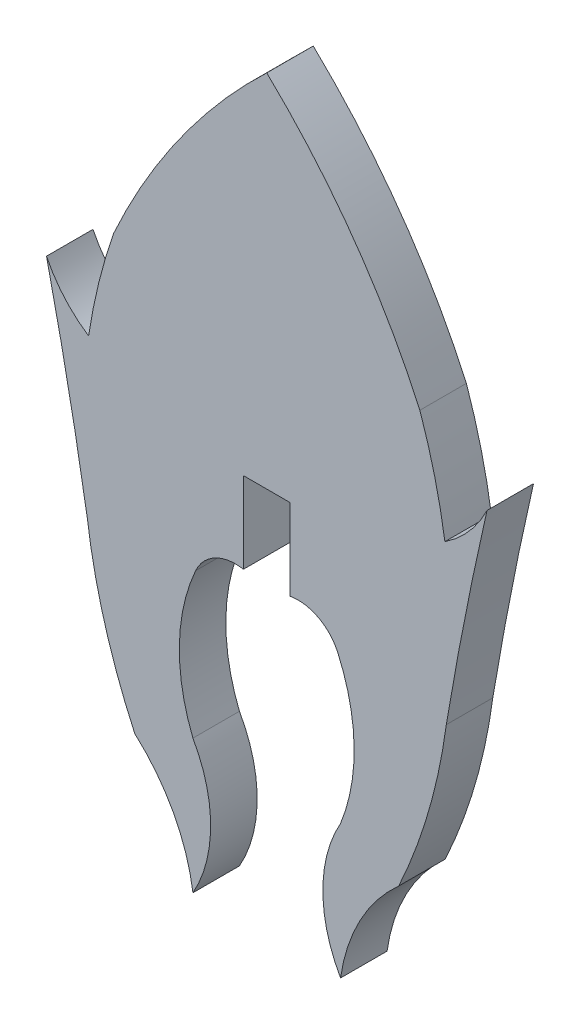
from build123d import *

# Parameters (mm, degrees)
BOSS_EXTRUDE1_DEPTH = 1.524


with BuildPart() as part:
    # Sketch1 → Boss-Extrude1 (new body)
    with BuildSketch(Plane.XY):
        with BuildLine():
            Line((0.762804565, 0.707113294), (0.762617378, -1.952243646))
            ThreePointArc((0.762617378, -1.952243646), (1.688876918, -2.090003107), (2.330283806, -2.772301873))
            ThreePointArc((2.330283806, -2.772301873), (2.864179893, -5.162377967), (2.419859411, -7.570715168))
            ThreePointArc((2.419859411, -7.570715168), (1.838969345, -9.764772757), (2.419550535, -11.958912099))
            ThreePointArc((2.419550535, -11.958912099), (3.056385936, -10.009011099), (4.324266146, -8.396512102))
            ThreePointArc((4.324266146, -8.396512102), (5.30756259, -5.77657732), (5.883862124, -3.038181986))
            ThreePointArc((5.883862124, -3.038181986), (6.501160971, 0.344941452), (7.217868451, 3.708408777))
            ThreePointArc((7.217868451, 3.708408777), (6.634279276, 2.828156935), (5.838122451, 2.134216059))
            ThreePointArc((5.838122451, 2.134216059), (5.505397312, 3.813158809), (5.018716283, 5.454102548))
            ThreePointArc((5.018716283, 5.454102548), (2.851221099, 9.229151646), (0.000807633, 12.519162913))
            ThreePointArc((0.000807633, 12.519162913), (-2.849605833, 9.229151646), (-5.017101017, 5.454102548))
            ThreePointArc((-5.017101017, 5.454102548), (-5.503782046, 3.813158809), (-5.836507185, 2.134216059))
            ThreePointArc((-5.836507185, 2.134216059), (-6.63266401, 2.828156935), (-7.216253185, 3.708408777))
            ThreePointArc((-7.216253185, 3.708408777), (-6.499545704, 0.344941452), (-5.882246858, -3.038181986))
            ThreePointArc((-5.882246858, -3.038181986), (-5.305947324, -5.77657732), (-4.32265088, -8.396512102))
            ThreePointArc((-4.32265088, -8.396512102), (-3.05477067, -10.009011099), (-2.417935269, -11.958912099))
            ThreePointArc((-2.417935269, -11.958912099), (-1.837354079, -9.764772757), (-2.418244145, -7.570715168))
            ThreePointArc((-2.418244145, -7.570715168), (-2.862564627, -5.162377967), (-2.32866854, -2.772301873))
            ThreePointArc((-2.32866854, -2.772301873), (-1.688352617, -2.090574399), (-0.763422707, -1.951788625))
            Line((-0.763422707, -1.951788625), (-0.761189299, 0.707113294))
            Line((-0.761189299, 0.707113294), (0.762804565, 0.707113294))
        make_face()
    extrude(amount=BOSS_EXTRUDE1_DEPTH)


solid = part.part
